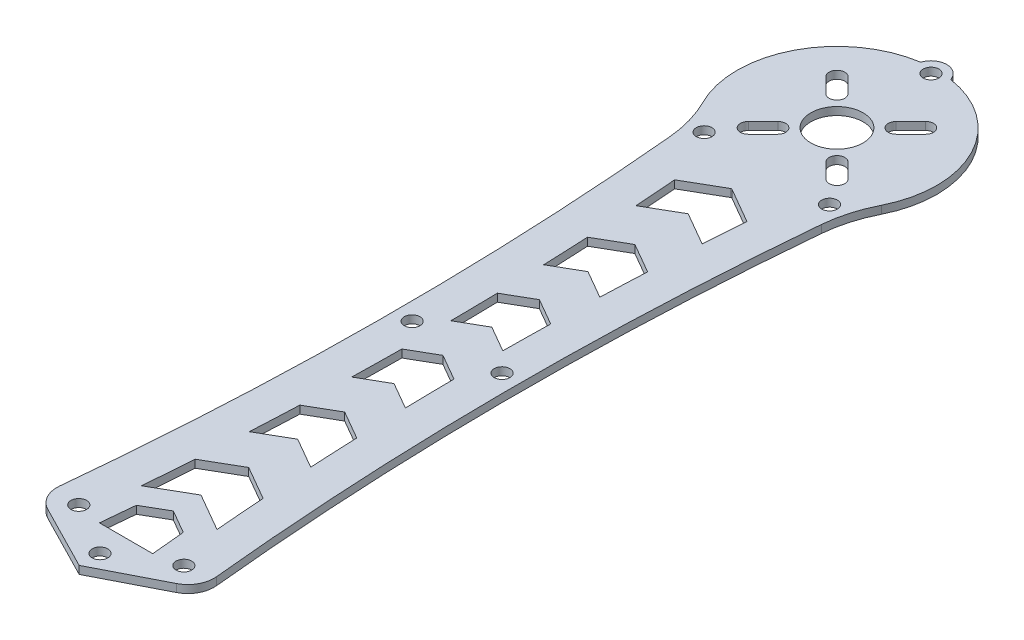
from build123d import *

# Parameters (mm, degrees)
SKETCH_1_R      = 1.5
SKETCH_1_R_2    = 5
EXTRUDE_1_DEPTH = 1.5


with BuildPart() as part:
    # 草圖1 → 填料-伸長1 (new body)
    with BuildSketch(Plane(origin=(0, 0, 0), x_dir=(1, 0, 0), z_dir=(0, 1, 0))):
        with BuildLine():
            Line((0, -3.980931511), (12.319060855, 2.328849967))
            ThreePointArc((12.319060855, 2.328849967), (14.431141465, 4.388450613), (15.014493405, 7.28025625))
            ThreePointArc((15.014493405, 7.28025625), (11.971039141, 65.394509034), (14.52184689, 123.53246884))
            ThreePointArc((14.52184689, 123.53246884), (15.377876917, 128.098069479), (17.067022361, 132.425226083))
            ThreePointArc((17.067022361, 132.425226083), (16.965589985, 149.77375384), (2.866920195, 159.883611111))
            ThreePointArc((2.866920195, 159.883611111), (0, 162), (-2.866920195, 159.883611111))
            ThreePointArc((-2.866920195, 159.883611111), (-16.965589985, 149.77375384), (-17.067022361, 132.425226083))
            ThreePointArc((-17.067022361, 132.425226083), (-15.377876917, 128.098069479), (-14.52184689, 123.53246884))
            ThreePointArc((-14.52184689, 123.53246884), (-11.971039141, 65.394509034), (-15.014493405, 7.28025625))
            ThreePointArc((-15.014493405, 7.28025625), (-14.431141465, 4.388450613), (-12.319060855, 2.328849967))
            Line((-12.319060855, 2.328849967), (0, -3.980931511))
        make_face()
        with Locations(Location((-12, 127.583592135, 0), (0, 0, 270))):
            Circle(SKETCH_1_R, mode=Mode.SUBTRACT)
        with Locations(Location((12, 127.583592135, 0), (0, 0, 270))):
            Circle(SKETCH_1_R, mode=Mode.SUBTRACT)
        with Locations(Location((8.6, 68.325395665, 0), (0, 0, 270))):
            Circle(SKETCH_1_R, mode=Mode.SUBTRACT)
        with Locations(Location((-8.6, 68.325395665, 0), (0, 0, 270))):
            Circle(SKETCH_1_R, mode=Mode.SUBTRACT)
        with Locations(Location((10.05, 6, 0), (0, 0, 270))):
            Circle(SKETCH_1_R, mode=Mode.SUBTRACT)
        with Locations(Location((-10.05, 6, 0), (0, 0, 270))):
            Circle(SKETCH_1_R, mode=Mode.SUBTRACT)
        with Locations(Location((0, 159, 0), (0, 0, 270))):
            Circle(SKETCH_1_R, mode=Mode.SUBTRACT)
        with Locations(Location((0, 0, 0), (0, 0, 270))):
            Circle(SKETCH_1_R, mode=Mode.SUBTRACT)
        with Locations(Location((0, 141, 0), (0, 0, 270))):
            Circle(SKETCH_1_R_2, mode=Mode.SUBTRACT)
        Polygon((0, 14.042409585), (-4.491071946, 11.449487988), (-5.101164168, 5.002829556), (5.101164168, 5.002829556), (4.491071946, 11.449487988), align=None, mode=Mode.SUBTRACT)
        with BuildLine():
            Line((0, 112.532142135), (-6.334048162, 108.875177723))
            ThreePointArc((-6.334048162, 108.875177723), (-6.614696141, 112.870067669), (-6.92146425, 116.863036776))
            Line((-6.92146425, 116.863036776), (-0.136378432, 120.780407899))
            ThreePointArc((-0.136378432, 120.780407899), (0, 120.816950389), (0.136378432, 120.780407899))
            Line((0.136378432, 120.780407899), (6.92146425, 116.863036776))
            ThreePointArc((6.92146425, 116.863036776), (6.614696141, 112.870067669), (6.334048162, 108.875177723))
            Line((6.334048162, 108.875177723), (0, 112.532142135))
        make_face(mode=Mode.SUBTRACT)
        with BuildLine():
            Line((0, 102.344922167), (5.753985291, 99.02285721))
            ThreePointArc((5.753985291, 99.02285721), (5.547257407, 94.643430297), (5.371890331, 90.262635518))
            Line((5.371890331, 90.262635518), (0, 93.364097846))
            Line((0, 93.364097846), (-5.371890331, 90.262635518))
            ThreePointArc((-5.371890331, 90.262635518), (-5.547257407, 94.643430297), (-5.753985291, 99.02285721))
            Line((-5.753985291, 99.02285721), (0, 102.344922167))
        make_face(mode=Mode.SUBTRACT)
        with BuildLine():
            Line((0, 84.072725452), (5.10712289, 81.124126676))
            ThreePointArc((5.10712289, 81.124126676), (5.026699976, 76.609736924), (4.97956534, 72.094876904))
            Line((4.97956534, 72.094876904), (0, 74.969830293))
            Line((0, 74.969830293), (-4.97956534, 72.094876904))
            ThreePointArc((-4.97956534, 72.094876904), (-5.026699976, 76.609736924), (-5.10712289, 81.124126676))
            Line((-5.10712289, 81.124126676), (0, 84.072725452))
        make_face(mode=Mode.SUBTRACT)
        with BuildLine():
            Line((0, 65.619773758), (4.987851065, 62.740036603))
            ThreePointArc((4.987851065, 62.740036603), (5.046332025, 58.016878131), (5.141244155, 53.29431128))
            Line((5.141244155, 53.29431128), (0, 56.262609977))
            Line((0, 56.262609977), (-5.141244155, 53.29431128))
            ThreePointArc((-5.141244155, 53.29431128), (-5.046332025, 58.016878131), (-4.987851065, 62.740036603))
            Line((-4.987851065, 62.740036603), (0, 65.619773758))
        make_face(mode=Mode.SUBTRACT)
        with BuildLine():
            Line((0, 46.827706802), (5.447027498, 43.68286401))
            ThreePointArc((5.447027498, 43.68286401), (5.648052955, 39.057684109), (5.884040018, 34.434156186))
            Line((5.884040018, 34.434156186), (0, 37.831308275))
            Line((0, 37.831308275), (-5.884040018, 34.434156186))
            ThreePointArc((-5.884040018, 34.434156186), (-5.648052955, 39.057684109), (-5.447027498, 43.68286401))
            Line((-5.447027498, 43.68286401), (0, 46.827706802))
        make_face(mode=Mode.SUBTRACT)
        with BuildLine():
            Line((0, 28.460830008), (6.494782795, 24.711065414))
            ThreePointArc((6.494782795, 24.711065414), (6.852315766, 19.927479382), (7.247310233, 15.146840877))
            Line((7.247310233, 15.146840877), (0, 19.331077391))
            Line((0, 19.331077391), (-7.247310233, 15.146840877))
            ThreePointArc((-7.247310233, 15.146840877), (-6.852315766, 19.927479382), (-6.494782795, 24.711065414))
            Line((-6.494782795, 24.711065414), (0, 28.460830008))
        make_face(mode=Mode.SUBTRACT)
        with BuildLine():
            Line((-6.717514421, 145.596194078), (-9.545941546, 148.424621202))
            ThreePointArc((-9.545941546, 148.424621202), (-9.545941546, 150.545941546), (-7.424621202, 150.545941546))
            Line((-7.424621202, 150.545941546), (-4.596194078, 147.717514421))
            ThreePointArc((-4.596194078, 147.717514421), (-4.596194078, 145.596194078), (-6.717514421, 145.596194078))
        make_face(mode=Mode.SUBTRACT)
        with BuildLine():
            Line((6.717514421, 145.596194078), (9.545941546, 148.424621202))
            ThreePointArc((9.545941546, 148.424621202), (9.545941546, 150.545941546), (7.424621202, 150.545941546))
            Line((7.424621202, 150.545941546), (4.596194078, 147.717514421))
            ThreePointArc((4.596194078, 147.717514421), (4.596194078, 145.596194078), (6.717514421, 145.596194078))
        make_face(mode=Mode.SUBTRACT)
        with BuildLine():
            Line((-4.596194078, 134.282485579), (-7.424621202, 131.454058454))
            ThreePointArc((-7.424621202, 131.454058454), (-9.545941546, 131.454058454), (-9.545941546, 133.575378798))
            Line((-9.545941546, 133.575378798), (-6.717514421, 136.403805922))
            ThreePointArc((-6.717514421, 136.403805922), (-4.596194078, 136.403805922), (-4.596194078, 134.282485579))
        make_face(mode=Mode.SUBTRACT)
        with BuildLine():
            Line((4.596194078, 134.282485579), (7.424621202, 131.454058454))
            ThreePointArc((7.424621202, 131.454058454), (9.545941546, 131.454058454), (9.545941546, 133.575378798))
            Line((9.545941546, 133.575378798), (6.717514421, 136.403805922))
            ThreePointArc((6.717514421, 136.403805922), (4.596194078, 136.403805922), (4.596194078, 134.282485579))
        make_face(mode=Mode.SUBTRACT)
    extrude(amount=EXTRUDE_1_DEPTH)


solid = part.part
